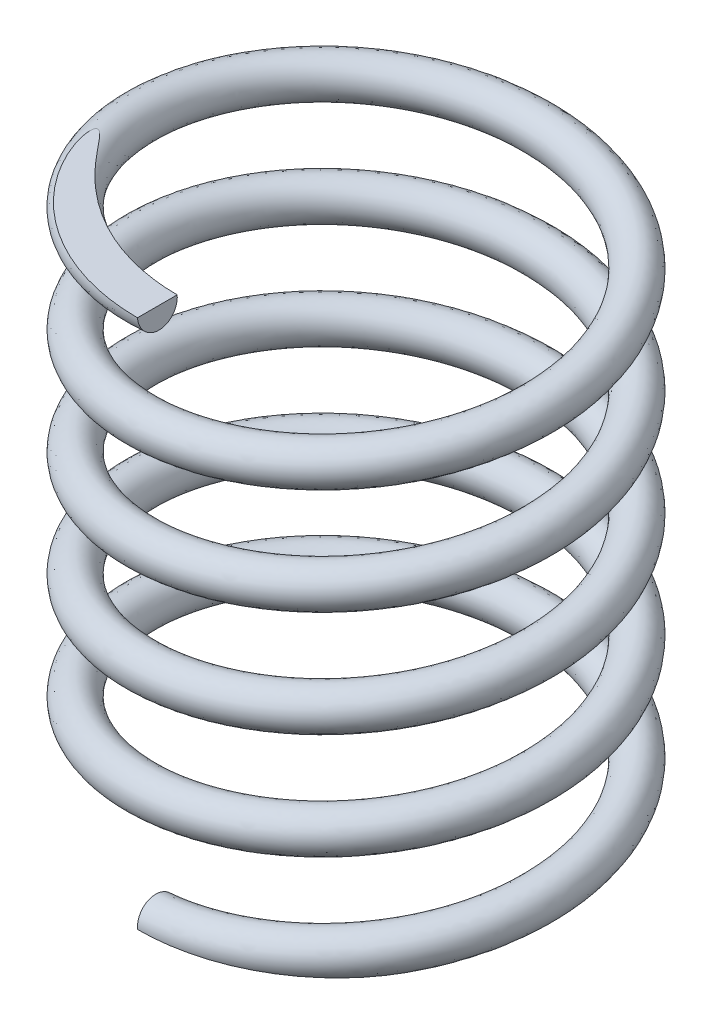
from build123d import *

# Parameters (mm, degrees)
SWEEP_1_PITCH       = 4
SWEEP_1_HEIGHT      = 20
SWEEP_1_RADIUS      = 7.5
SKETCH_5_R          = 0.75
SKETCH_6_R          = 10.337728571
CUT_EXTRUDE_1_DEPTH = 10
SKETCH_7_R          = 10.142927146
CUT_EXTRUDE_2_DEPTH = 10


with BuildPart() as part:
    # По траектории1: sweep along a helix
    with BuildLine() as sweep_1_path:
        Helix(SWEEP_1_PITCH, SWEEP_1_HEIGHT, SWEEP_1_RADIUS, center=(0, 0, 0), direction=(0, 1, 0))
    # Эскиз5 → По траектории1 (sweep)
    with BuildSketch(Plane(origin=(0, 0, 7.5), x_dir=(0, 0, -1), z_dir=(0.99641682, 0.084578487, 0))):
        Circle(SKETCH_5_R)
    sweep(path=sweep_1_path.line, is_frenet=True)

    # Эскиз6 → Вырез-Вытянуть1 (cut)
    with BuildSketch(Plane(origin=(0, 0, 0), x_dir=(1, 0, 0), z_dir=(0, 1, 0))):
        Circle(SKETCH_6_R)
    extrude(amount=-CUT_EXTRUDE_1_DEPTH, mode=Mode.SUBTRACT)

    # Эскиз7 → Вырез-Вытянуть2 (cut)
    with BuildSketch(Plane(origin=(0, 20, 0), x_dir=(1, 0, 0), z_dir=(0, 1, 0))):
        Circle(SKETCH_7_R)
    extrude(amount=CUT_EXTRUDE_2_DEPTH, mode=Mode.SUBTRACT)


solid = part.part
